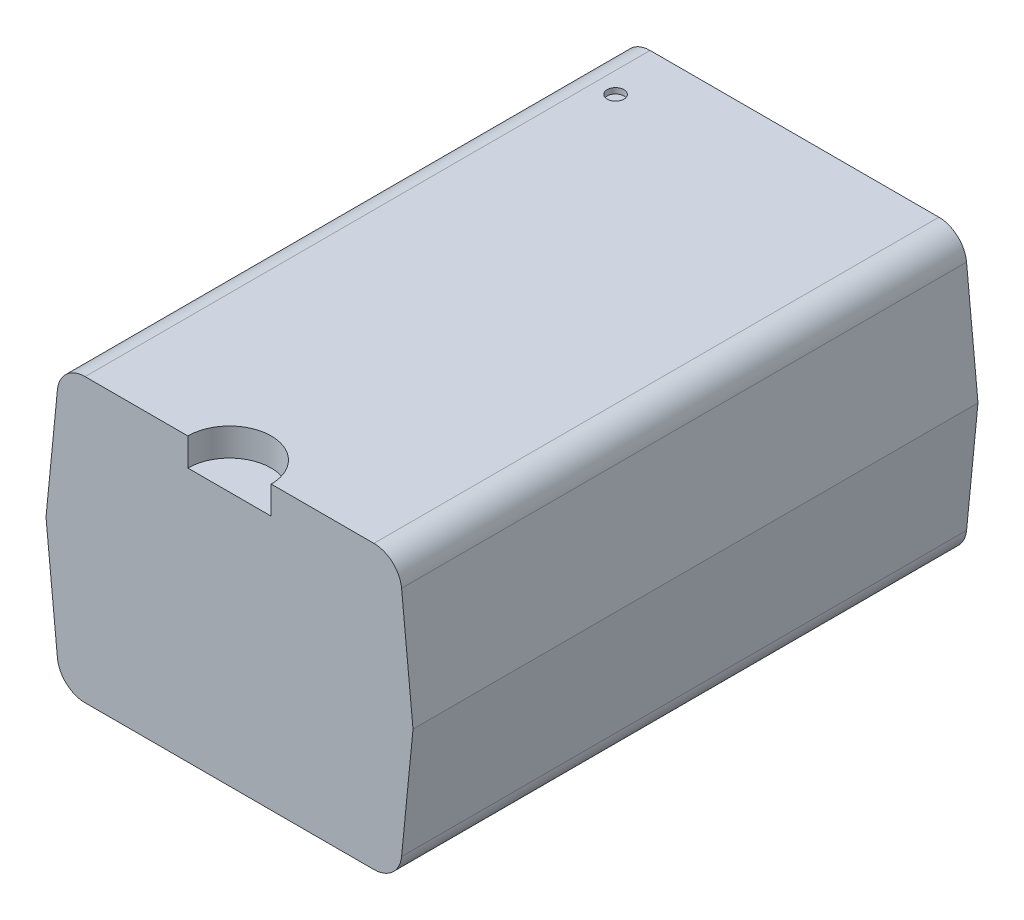
from build123d import *

# Parameters (mm, degrees)
BOSS_EXTRUDE1_DEPTH = 10.16
FILLET1_R           = 0.5
SKETCH36_R          = 0.15
CUT_EXTRUDE26_DEPTH = 0.1
SKETCH37_R          = 0.75
CUT_EXTRUDE27_DEPTH = 0.5


with BuildPart() as part:
    # Sketch1 → Boss-Extrude1 (new body)
    with BuildSketch(Plane.XY):
        Polygon((-33.789176406, 21.191188847), (-27.689176406, 21.191188847), (-27.439176406, 18.651188847), (-27.689176406, 16.111188847), (-33.789176406, 16.111188847), (-34.039176406, 18.651188847), align=None)
    extrude(amount=BOSS_EXTRUDE1_DEPTH)

    # Fillet1
    fillet1_edges = [part.edges().sort_by_distance(p)[0] for p in [
        (-33.789176406, 21.191188847, 5.08),
        (-27.689176406, 21.191188847, 5.08),
        (-27.689176406, 16.111188847, 5.08),
        (-33.789176406, 16.111188847, 5.08),
    ]]
    fillet(fillet1_edges, radius=FILLET1_R)

    # Sketch36 → Cut-Extrude26 (cut)
    with BuildSketch(Plane(origin=(0, 21.191188847, 0), x_dir=(1, 0, 0), z_dir=(0, 1, 0))):
        with Locations((-32.962004814, -0.994910083)):
            Circle(SKETCH36_R)
    extrude(amount=-CUT_EXTRUDE26_DEPTH, mode=Mode.SUBTRACT)

    # Sketch37 → Cut-Extrude27 (cut)
    with BuildSketch(Plane(origin=(0, 21.191188847, 0), x_dir=(1, 0, 0), z_dir=(0, 1, 0))):
        with Locations((-30.739176406, -10.16)):
            Circle(SKETCH37_R)
    extrude(amount=-CUT_EXTRUDE27_DEPTH, mode=Mode.SUBTRACT)


solid = part.part
